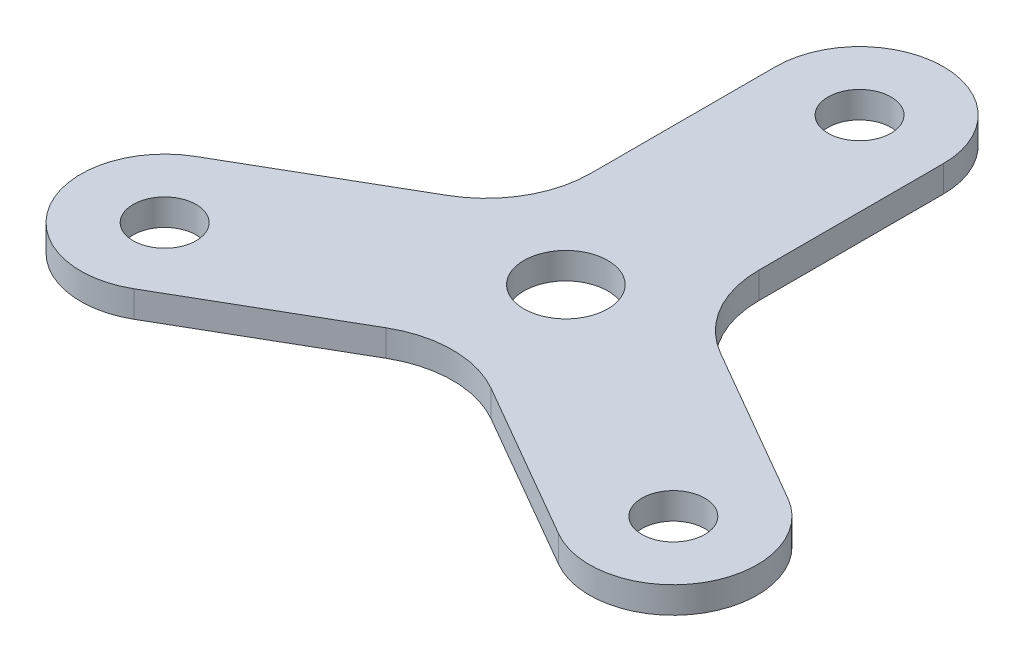
from build123d import *

# Parameters (mm, degrees)
SKETCH1_R           = 1.905
BOSS_EXTRUDE1_DEPTH = 0.8001
CIRPATTERN1_COUNT   = 3
SKETCH2_R           = 2.54
CUT_EXTRUDE1_DEPTH  = 2.6002
FILLET1_R           = 6.35


with BuildPart() as part:
    # Sketch1 → Boss-Extrude1 (new body, symmetric)
    with BuildSketch(Plane(origin=(0, 0, 0), x_dir=(1, 0, 0), z_dir=(0, 1, 0))):
        with BuildLine():
            Line((-5.08, 17.78), (-5.08, 0))
            Line((-5.08, 0), (5.08, 0))
            Line((5.08, 0), (5.08, 17.78))
            ThreePointArc((5.08, 17.78), (0, 22.86), (-5.08, 17.78))
        make_face()
        with Locations((0, 17.78)):
            Circle(SKETCH1_R, mode=Mode.SUBTRACT)
    boss_extrude1 = extrude(amount=BOSS_EXTRUDE1_DEPTH, both=True)

    # CirPattern1: Boss-Extrude1 ×3 about axis
    cirpattern1_axis = Axis((0, 0, 0), (0, 1, 0))
    for i in range(1, CIRPATTERN1_COUNT):
        add(boss_extrude1.rotate(cirpattern1_axis, i * 360 / CIRPATTERN1_COUNT))

    # Sketch2 → Cut-Extrude1 (cut, through all)
    with BuildSketch(Plane(origin=(0, 0.8001, 0), x_dir=(1, 0, 0), z_dir=(0, 1, 0))):
        Circle(SKETCH2_R)
    extrude(amount=-CUT_EXTRUDE1_DEPTH, mode=Mode.SUBTRACT)

    # Fillet1
    fillet1_edges = [part.edges().sort_by_distance(p)[0] for p in [
        (5.08, 0, -2.932939367),
        (-5.08, 0, -2.932939367),
        (0, 0, 5.865878735),
    ]]
    fillet(fillet1_edges, radius=FILLET1_R)


solid = part.part
